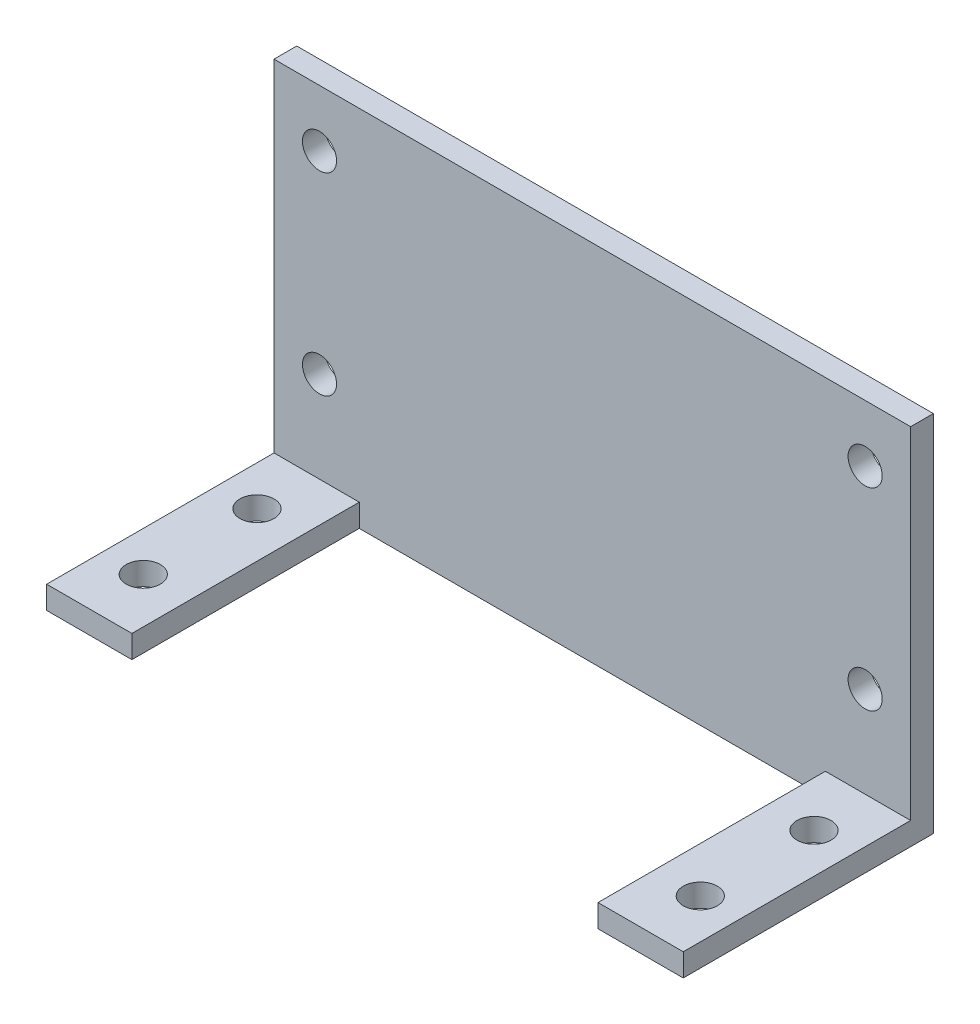
from build123d import *

# Parameters (mm, degrees)
ESQUISSE1_W             = 56
ESQUISSE1_H             = 22
BOSS_EXTRU_1_DEPTH      = 2
ESQUISSE2_W             = 56
ESQUISSE2_H             = 2
BOSS_EXTRU_2_DEPTH      = 30
ESQUISSE3_W             = 41
ESQUISSE3_H             = 20
ENL_V_MAT_EXTRU_1_DEPTH = 20
ESQUISSE5_R             = 1.5
ENL_V_MAT_EXTRU_2_DEPTH = 20
ESQUISSE6_R             = 1.5
ENL_V_MAT_EXTRU_3_DEPTH = 20


with BuildPart() as part:
    # Esquisse1 → Boss.-Extru.1 (new body)
    with BuildSketch(Plane(origin=(0, 0, 0), x_dir=(1, 0, 0), z_dir=(0, 1, 0))):
        Rectangle(ESQUISSE1_W, ESQUISSE1_H)
    extrude(amount=BOSS_EXTRU_1_DEPTH)

    # Esquisse2 → Boss.-Extru.2 (add)
    with BuildSketch(Plane(origin=(0, 2, 0), x_dir=(1, 0, 0), z_dir=(0, 1, 0))):
        with Locations((0, 10)):
            Rectangle(ESQUISSE2_W, ESQUISSE2_H)
    extrude(amount=BOSS_EXTRU_2_DEPTH)

    # Esquisse3 → Enlèv. mat.-Extru.1 (cut)
    with BuildSketch(Plane(origin=(0, 2, 0), x_dir=(1, 0, 0), z_dir=(0, 1, 0))):
        with Locations((0, -1)):
            Rectangle(ESQUISSE3_W, ESQUISSE3_H)
    extrude(amount=-ENL_V_MAT_EXTRU_1_DEPTH, mode=Mode.SUBTRACT)

    # Esquisse5 → Enlèv. mat.-Extru.2 (cut)
    with BuildSketch(Plane(origin=(0, 2, 0), x_dir=(1, 0, 0), z_dir=(0, 1, 0))):
        with Locations((-24.5, 4)):
            Circle(ESQUISSE5_R)
        with Locations((-24.5, -6)):
            Circle(ESQUISSE5_R)
        with Locations((24.5, 4)):
            Circle(ESQUISSE5_R)
        with Locations((24.5, -6)):
            Circle(ESQUISSE5_R)
    extrude(amount=-ENL_V_MAT_EXTRU_2_DEPTH, mode=Mode.SUBTRACT)

    # Esquisse6 → Enlèv. mat.-Extru.3 (cut)
    with BuildSketch(Plane(origin=(0, 0, -11), x_dir=(-1, 0, 0), z_dir=(0, 0, -1))):
        with Locations((-24, 27)):
            Circle(ESQUISSE6_R)
        with Locations((-24, 10)):
            Circle(ESQUISSE6_R)
        with Locations((24, 10)):
            Circle(ESQUISSE6_R)
        with Locations((24, 27)):
            Circle(ESQUISSE6_R)
    extrude(amount=-ENL_V_MAT_EXTRU_3_DEPTH, mode=Mode.SUBTRACT)


solid = part.part
